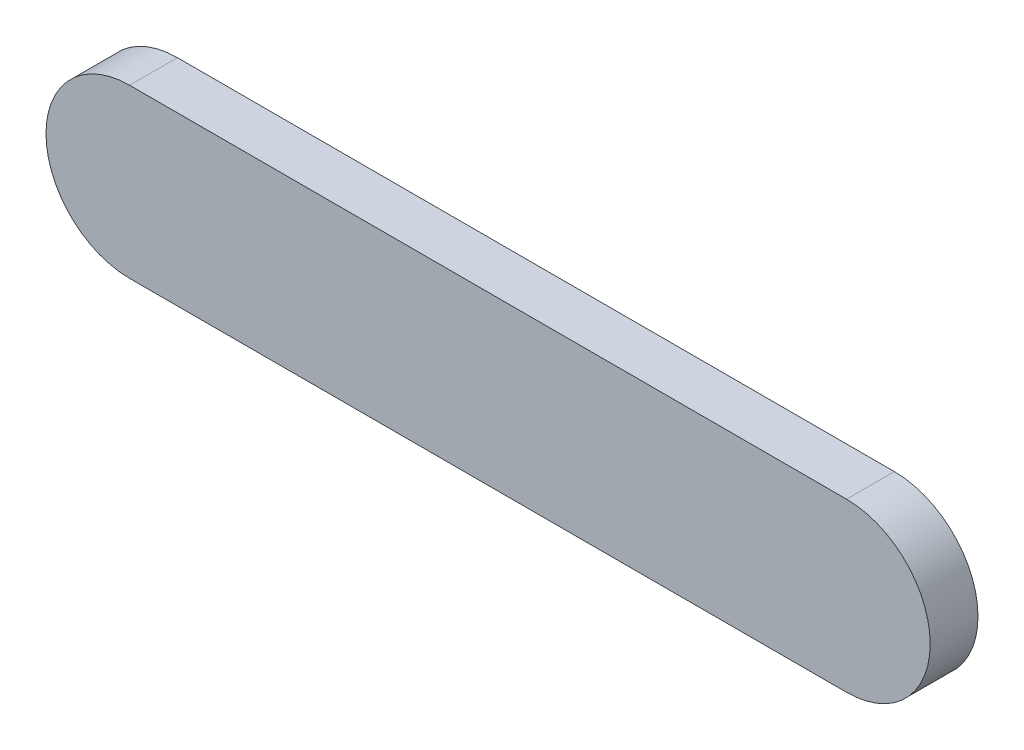
from build123d import *

# Parameters (mm, degrees)
EXTRUDE_1_DEPTH = 12


with BuildPart() as part:
    # 草图2 → 凸台-拉伸1 (new body)
    with BuildSketch(Plane.XY):
        with BuildLine():
            Line((-90, 21), (90, 21))
            ThreePointArc((90, 21), (111, 0), (90, -21))
            Line((90, -21), (-90, -21))
            ThreePointArc((-90, -21), (-111, 0), (-90, 21))
        make_face()
    extrude(amount=EXTRUDE_1_DEPTH)


solid = part.part
